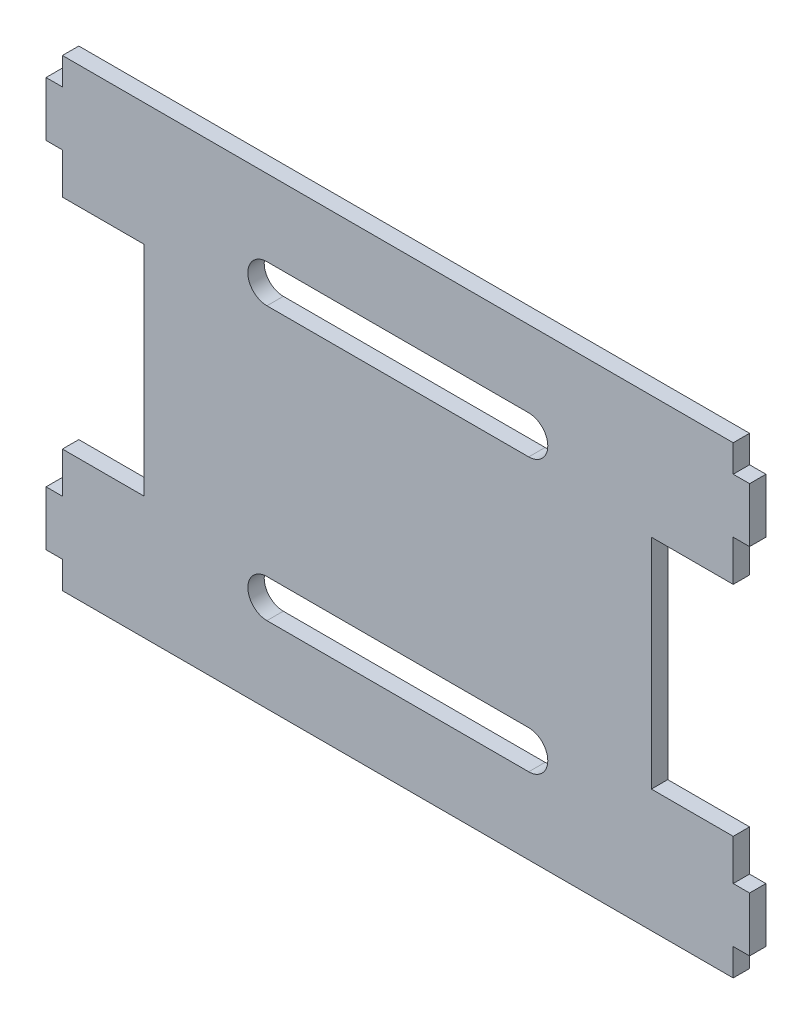
from build123d import *

# Parameters (mm, degrees)
BOSS_EXTRUDE3_DEPTH = 3


with BuildPart() as part:
    # Sketch1 → Boss-Extrude3 (new body)
    with BuildSketch(Plane.XY):
        Polygon((-61.5, 27.5), (-61.5, 20), (-46.5, 20), (-46.5, -20), (-61.5, -20), (-61.5, -27.5), (-64.5, -27.5), (-64.5, -37.5), (-61.5, -37.5), (-61.5, -42.5), (61.5, -42.5), (61.5, -37.5), (64.5, -37.5), (64.5, -27.5), (61.5, -27.5), (61.5, -20), (46.5, -20), (46.5, 20), (61.5, 20), (61.5, 27.5), (64.5, 27.5), (64.5, 37.5), (61.5, 37.5), (61.5, 42.5), (-61.5, 42.5), (-61.5, 37.5), (-64.5, 37.5), (-64.5, 27.5), align=None)
        with BuildLine():
            Line((-24, 28.5), (24, 28.5))
            ThreePointArc((24, 28.5), (27.5, 25), (24, 21.5))
            Line((24, 21.5), (-24, 21.5))
            ThreePointArc((-24, 21.5), (-27.5, 25), (-24, 28.5))
        make_face(mode=Mode.SUBTRACT)
        with BuildLine():
            Line((-24, -21.5), (24, -21.5))
            ThreePointArc((24, -21.5), (27.5, -25), (24, -28.5))
            Line((24, -28.5), (-24, -28.5))
            ThreePointArc((-24, -28.5), (-27.5, -25), (-24, -21.5))
        make_face(mode=Mode.SUBTRACT)
    extrude(amount=BOSS_EXTRUDE3_DEPTH)


solid = part.part
